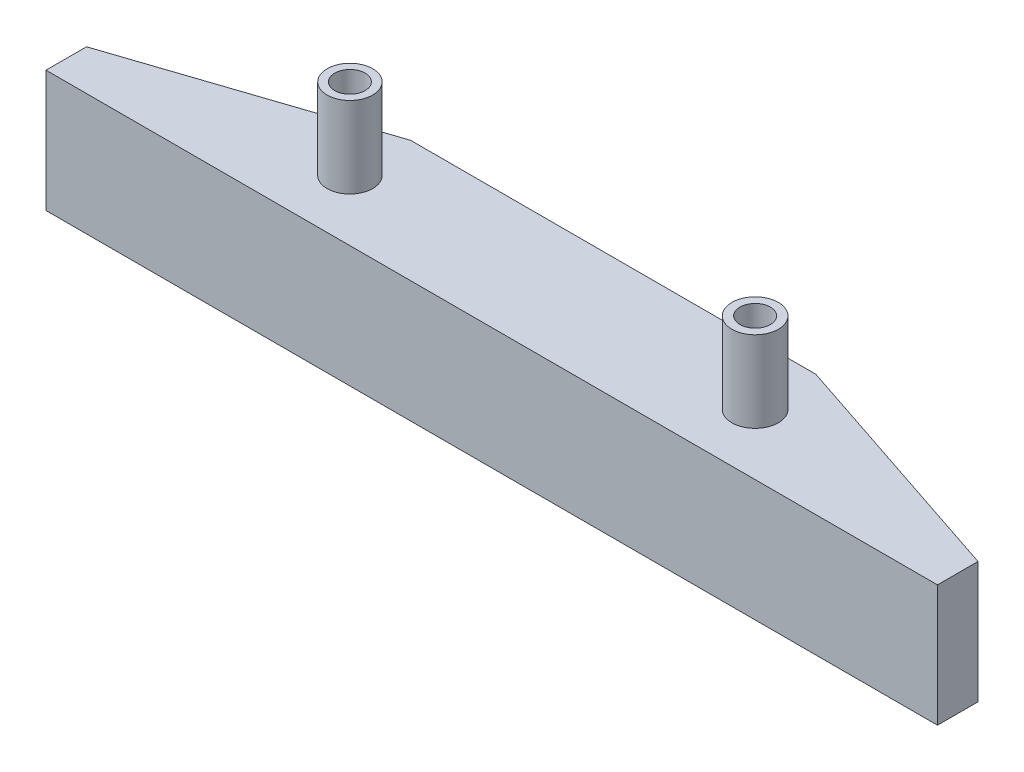
from build123d import *

# Parameters (mm, degrees)
BOSS_EXTRUDE1_DEPTH = 12
SKETCH2_R           = 2.5
CUT_EXTRUDE1_DEPTH  = 5
SKETCH3_R           = 1.5
CUT_EXTRUDE2_DEPTH  = 90.089842294
SKETCH4_R           = 2.25
SKETCH4_R_2         = 1.5
SKETCH4_R_3         = 2.294622505
BOSS_EXTRUDE2_DEPTH = 8


with BuildPart() as part:
    # Sketch1 → Boss-Extrude1 (new body)
    with BuildSketch(Plane(origin=(0, 0, 0), x_dir=(1, 0, 0), z_dir=(0, 1, 0))):
        Polygon((0, 0), (88, 0), (88, 4), (64, 12), (24, 12), (0, 4), align=None)
    extrude(amount=BOSS_EXTRUDE1_DEPTH)

    # Sketch2 → Cut-Extrude1 (cut)
    with BuildSketch(Plane(origin=(0, 0, 0), x_dir=(-1, 0, 0), z_dir=(0, -1, 0))):
        with Locations(Location((-24, 6, 0), (0, 0, 90))):
            Circle(SKETCH2_R)
        with Locations(Location((-64, 6, 0), (0, 0, 90))):
            Circle(SKETCH2_R)
    extrude(amount=-CUT_EXTRUDE1_DEPTH, mode=Mode.SUBTRACT)

    # Sketch3 → Cut-Extrude2 (cut, through all)
    with BuildSketch(Plane(origin=(0, 5, 0), x_dir=(-1, 0, 0), z_dir=(0, -1, 0))):
        with Locations(Location((-24, 6, 0), (0, 0, 90))):
            Circle(SKETCH3_R)
        with Locations(Location((-64, 6, 0), (0, 0, 90))):
            Circle(SKETCH3_R)
    extrude(amount=-CUT_EXTRUDE2_DEPTH, mode=Mode.SUBTRACT)

    # Sketch4 → Boss-Extrude2 (add)
    with BuildSketch(Plane(origin=(0, 12, 0), x_dir=(1, 0, 0), z_dir=(0, 1, 0))):
        with Locations(Location((24, 6, 0), (0, 0, 270))):
            Circle(SKETCH4_R)
        with Locations(Location((24, 6, 0), (0, 0, 90))):
            Circle(SKETCH4_R_2, mode=Mode.SUBTRACT)
        with Locations(Location((64, 6, 0), (0, 0, 270))):
            Circle(SKETCH4_R_3)
        with Locations(Location((64, 6, 0), (0, 0, 90))):
            Circle(SKETCH4_R_2, mode=Mode.SUBTRACT)
    extrude(amount=BOSS_EXTRUDE2_DEPTH)


solid = part.part
